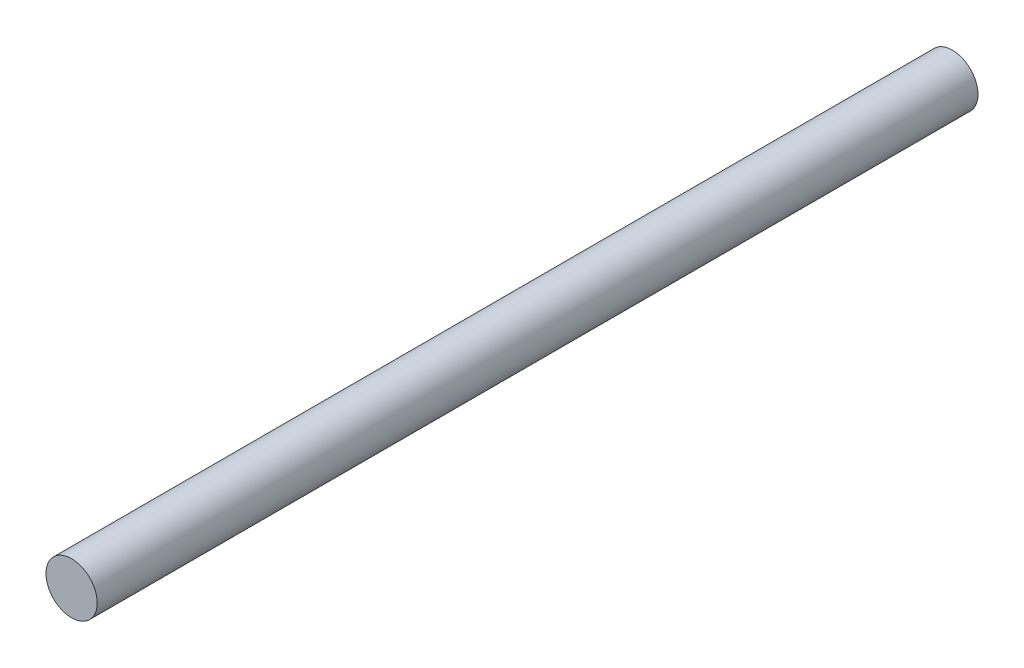
from build123d import *

# Parameters (mm, degrees)
SKETCH1_R           = 4
BOSS_EXTRUDE1_DEPTH = 137.5


with BuildPart() as part:
    # Sketch1 → Boss-Extrude1 (new body)
    with BuildSketch(Plane.XY):
        Circle(SKETCH1_R)
    extrude(amount=BOSS_EXTRUDE1_DEPTH)


solid = part.part
